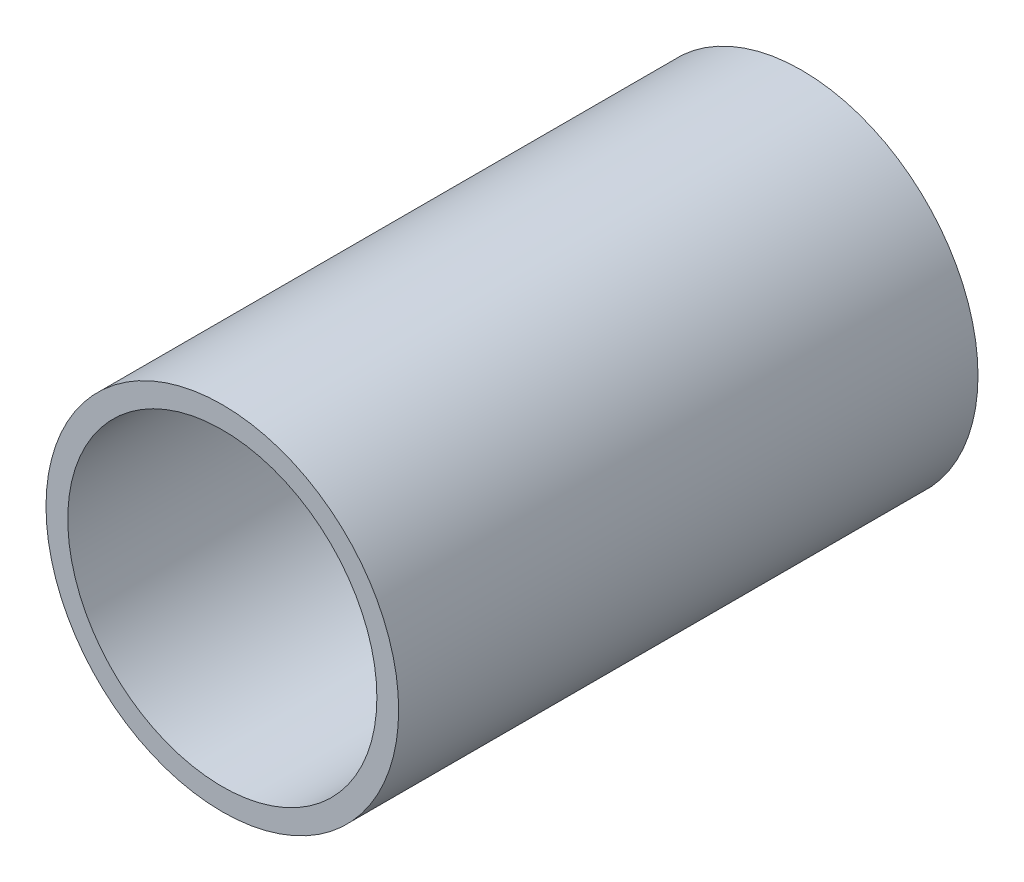
from build123d import *

# Parameters (mm, degrees)
SKETCH1_R           = 44.45
SKETCH1_R_2         = 38.9636
EXTRUDE_THIN1_DEPTH = 73.025


with BuildPart() as part:
    # Sketch1 → Extrude-Thin1 (new body, symmetric)
    with BuildSketch(Plane.XY):
        Circle(SKETCH1_R)
        Circle(SKETCH1_R_2, mode=Mode.SUBTRACT)
    extrude(amount=EXTRUDE_THIN1_DEPTH, both=True)


solid = part.part
